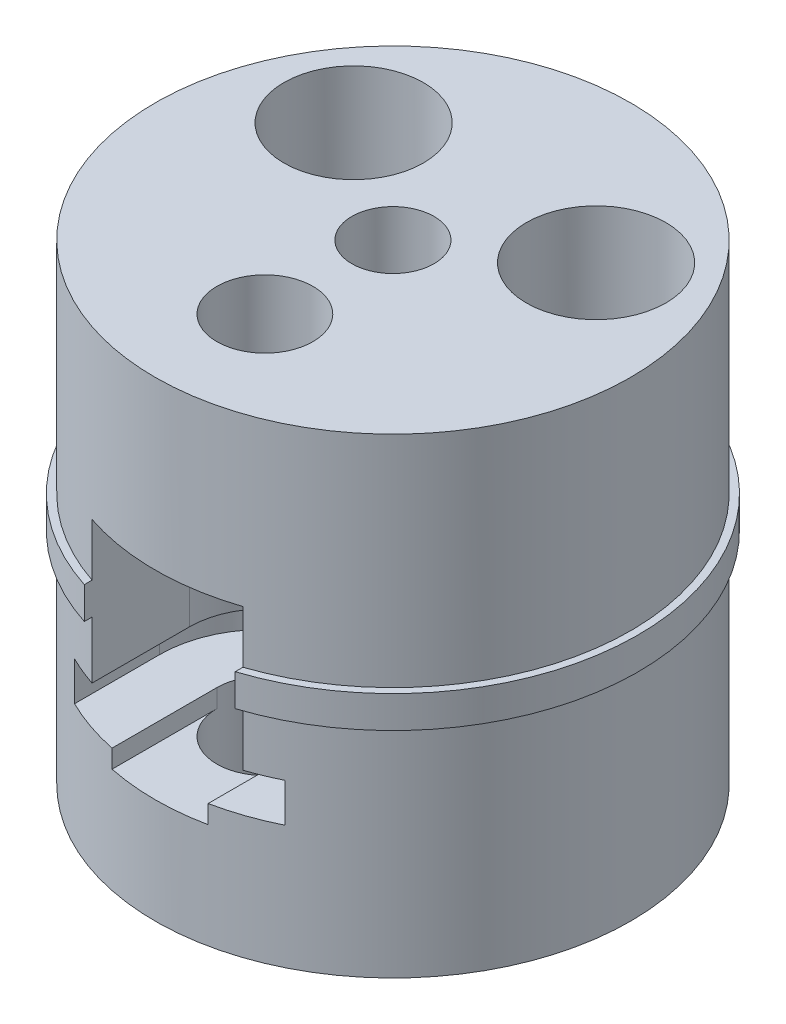
from build123d import *

# Parameters (mm, degrees)
SKETCH1_R           = 26.797
BOSS_EXTRUDE1_DEPTH = 3.5
SKETCH2_R           = 25.9969
BOSS_EXTRUDE2_DEPTH = 24
SKETCH3_R           = 25.9969
BOSS_EXTRUDE3_DEPTH = 24
SKETCH4_R           = 7.625
CUT_EXTRUDE1_DEPTH  = 24
SKETCH5_R           = 7.625
SKETCH5_R_2         = 4.490128061
CUT_EXTRUDE2_DEPTH  = 24
SKETCH6_R           = 5.25
SKETCH6_R_2         = 5
CUT_EXTRUDE4_DEPTH  = 52.5
CUT_EXTRUDE5_START  = -26.797
SKETCH7_W           = 16.5
SKETCH7_H           = 5.75
CUT_EXTRUDE5_DEPTH  = 25.9969
CUT_EXTRUDE6_DEPTH  = 5.75
SKETCH13_W          = 16.5
SKETCH13_H          = 9.75
CUT_EXTRUDE10_DEPTH = 12.797
CUT_EXTRUDE11_DEPTH = 9.75
SKETCH9_W           = 23
SKETCH9_H           = 4.25
CUT_EXTRUDE7_DEPTH  = 12.797
CUT_EXTRUDE8_DEPTH  = 4.25
CUT_EXTRUDE9_START  = -12.797
SKETCH12_W          = 10.5
SKETCH12_H          = 2
CUT_EXTRUDE9_DEPTH  = 11.9969


with BuildPart() as part:
    # Sketch1 → Boss-Extrude1 (new body)
    with BuildSketch(Plane(origin=(0, 0, 0), x_dir=(1, 0, 0), z_dir=(0, 1, 0))):
        Circle(SKETCH1_R)
    extrude(amount=BOSS_EXTRUDE1_DEPTH)

    # Sketch2 → Boss-Extrude2 (add)
    with BuildSketch(Plane(origin=(0, 3.5, 0), x_dir=(1, 0, 0), z_dir=(0, 1, 0))):
        Circle(SKETCH2_R)
    extrude(amount=BOSS_EXTRUDE2_DEPTH)

    # Sketch3 → Boss-Extrude3 (add)
    with BuildSketch(Plane.XZ):
        Circle(SKETCH3_R)
    extrude(amount=BOSS_EXTRUDE3_DEPTH)

    # Sketch4 → Cut-Extrude1 (cut)
    with BuildSketch(Plane.XZ.offset(24)):
        with Locations((-13.255925111, -8.959935794)):
            Circle(SKETCH4_R)
        with Locations((13.255925111, -8.959935794)):
            Circle(SKETCH4_R)
    extrude(amount=-CUT_EXTRUDE1_DEPTH, mode=Mode.SUBTRACT)

    # Sketch5 → Cut-Extrude2 (cut)
    with BuildSketch(Plane(origin=(0, 27.5, -30.35), x_dir=(-1, 0, 0), z_dir=(0, -1, 0))):
        with Locations((-13.255925111, -21.390064206)):
            Circle(SKETCH5_R)
        with Locations((13.255925111, -21.390064206)):
            Circle(SKETCH5_R)
        with Locations((0, -30.35)):
            Circle(SKETCH5_R_2)
    extrude(amount=CUT_EXTRUDE2_DEPTH, mode=Mode.SUBTRACT)

    # Sketch6 → Cut-Extrude4 (cut, through all)
    with BuildSketch(Plane(origin=(0, -24, -24), x_dir=(-1, 0, 0), z_dir=(0, 1, 0))):
        with Locations((0, 38)):
            Circle(SKETCH6_R)
        with Locations((-13.255925111, 15.040064206)):
            Circle(SKETCH6_R_2)
        with Locations((13.255925111, 15.040064206)):
            Circle(SKETCH6_R_2)
    extrude(amount=CUT_EXTRUDE4_DEPTH, mode=Mode.SUBTRACT)

    # Sketch7 → Cut-Extrude5 (cut)
    with BuildSketch(Plane.XY.offset(26.797).offset(CUT_EXTRUDE5_START)):
        with Locations((0, 6.375)):
            Rectangle(SKETCH7_W, SKETCH7_H)
    extrude(amount=CUT_EXTRUDE5_DEPTH, mode=Mode.SUBTRACT)

    # Sketch8 → Cut-Extrude6 (cut)
    with BuildSketch(Plane(origin=(0, 3.5, 0), x_dir=(1, 0, 0), z_dir=(0, 1, 0))):
        with BuildLine():
            Line((-8.25, 0), (8.25, 0))
            ThreePointArc((8.25, 0), (0, 8.25), (-8.25, 0))
        make_face()
    extrude(amount=CUT_EXTRUDE6_DEPTH, mode=Mode.SUBTRACT)

    # Sketch13 → Cut-Extrude10 (cut)
    with BuildSketch(Plane.XY.offset(26.797)):
        with Locations((0, -1.375)):
            Rectangle(SKETCH13_W, SKETCH13_H)
    extrude(amount=-CUT_EXTRUDE10_DEPTH, mode=Mode.SUBTRACT)

    # Sketch14 → Cut-Extrude11 (cut)
    with BuildSketch(Plane(origin=(0, -6.25, 0), x_dir=(1, 0, 0), z_dir=(0, 1, 0))):
        with BuildLine():
            Line((-8.25, -14), (8.25, -14))
            ThreePointArc((8.25, -14), (0, -5.75), (-8.25, -14))
        make_face()
    extrude(amount=CUT_EXTRUDE11_DEPTH, mode=Mode.SUBTRACT)

    # Sketch9 → Cut-Extrude7 (cut)
    with BuildSketch(Plane.XY.offset(26.797)):
        with Locations((0, -8.375)):
            Rectangle(SKETCH9_W, SKETCH9_H)
    extrude(amount=-CUT_EXTRUDE7_DEPTH, mode=Mode.SUBTRACT)

    # Sketch11 → Cut-Extrude8 (cut)
    with BuildSketch(Plane(origin=(0, -10.5, 0), x_dir=(1, 0, 0), z_dir=(0, 1, 0))):
        with BuildLine():
            Line((-11.5, -14), (11.5, -14))
            ThreePointArc((11.5, -14), (0, -2.5), (-11.5, -14))
        make_face()
    extrude(amount=CUT_EXTRUDE8_DEPTH, mode=Mode.SUBTRACT)

    # Sketch12 → Cut-Extrude9 (cut)
    with BuildSketch(Plane.XY.offset(26.797).offset(CUT_EXTRUDE9_START)):
        with Locations((0, -11.5)):
            Rectangle(SKETCH12_W, SKETCH12_H)
    extrude(amount=CUT_EXTRUDE9_DEPTH, mode=Mode.SUBTRACT)


solid = part.part
